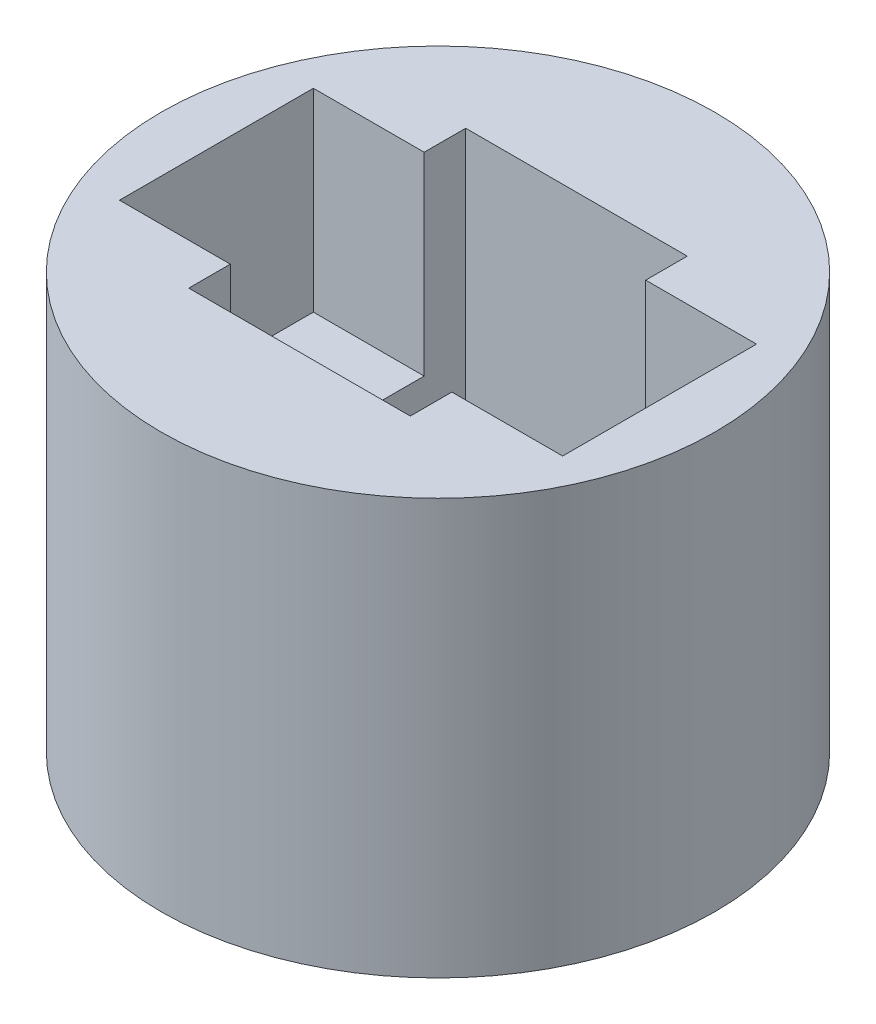
from build123d import *

# Parameters (mm, degrees)
CROQUIS1_W            = 5
CROQUIS1_H            = 7.5
CROQUIS2_R            = 0.5
CROQUIS2_W            = 4
CROQUIS2_H            = 1
CROQUIS2_H_2          = 2
CORTAR_EXTRUIR1_DEPTH = 8.5
CROQUIS3_W            = 8
CROQUIS3_H            = 3.5
CORTAR_EXTRUIR2_DEPTH = 3.5


with BuildPart() as part:
    # Croquis1 → Revolución1 (revolve)
    with BuildSketch(Plane.XY):
        with Locations((2.5, 3.75)):
            Rectangle(CROQUIS1_W, CROQUIS1_H)
    revolve(axis=Axis((0, 0, 0), (0, 1, 0)))

    # Croquis2 → Cortar-Extruir1 (cut, through all)
    with BuildSketch(Plane(origin=(0, 7.5, 0), x_dir=(1, 0, 0), z_dir=(0, 1, 0))):
        with Locations((-3, 0)):
            Circle(CROQUIS2_R)
        with BuildLine():
            Line((-2, 0.5), (-3, 0.5))
            ThreePointArc((-3, 0.5), (-2.646446609, 0.353553391), (-2.5, 0))
            ThreePointArc((-2.5, 0), (-2.646446609, -0.353553391), (-3, -0.5))
            Line((-3, -0.5), (-2, -0.5))
            Line((-2, -0.5), (-2, 0.5))
        make_face()
        Rectangle(CROQUIS2_W, CROQUIS2_H)
        with Locations((0, 1.5)):
            Rectangle(CROQUIS2_W, CROQUIS2_H_2)
        with Locations((0, -1.5)):
            Rectangle(CROQUIS2_W, CROQUIS2_H_2)
        with BuildLine():
            Line((3, 0.5), (2, 0.5))
            Line((2, 0.5), (2, -0.5))
            Line((2, -0.5), (3, -0.5))
            ThreePointArc((3, -0.5), (2.5, 0), (3, 0.5))
        make_face()
        with Locations((3, 0)):
            Circle(CROQUIS2_R)
    extrude(amount=-CORTAR_EXTRUIR1_DEPTH, mode=Mode.SUBTRACT)

    # Croquis3 → Cortar-Extruir2 (cut)
    with BuildSketch(Plane(origin=(0, 7.5, 0), x_dir=(1, 0, 0), z_dir=(0, 1, 0))):
        Rectangle(CROQUIS3_W, CROQUIS3_H)
    extrude(amount=-CORTAR_EXTRUIR2_DEPTH, mode=Mode.SUBTRACT)


solid = part.part
